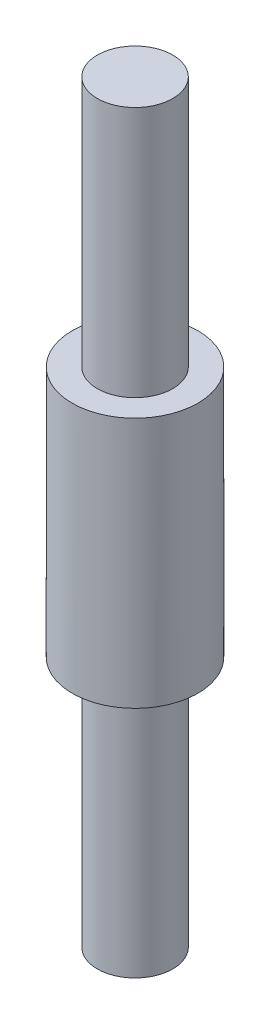
from build123d import *

# Parameters (mm, degrees)
SKETCH1_R           = 2.5
BOSS_EXTRUDE1_DEPTH = 15
SKETCH2_R           = 12.5
SKETCH2_R_2         = 1.5
CUT_EXTRUDE1_DEPTH  = 10


with BuildPart() as part:
    # Sketch1 → Boss-Extrude1 (new body, symmetric)
    with BuildSketch(Plane(origin=(0, 0, 0), x_dir=(1, 0, 0), z_dir=(0, 1, 0))):
        Circle(SKETCH1_R)
    extrude(amount=BOSS_EXTRUDE1_DEPTH, both=True)

    # Sketch2 → Cut-Extrude1 (cut)
    with BuildSketch(Plane(origin=(0, 15, 0), x_dir=(1, 0, 0), z_dir=(0, 1, 0))):
        Circle(SKETCH2_R)
        Circle(SKETCH2_R_2, mode=Mode.SUBTRACT)
    cut_extrude1 = extrude(amount=-CUT_EXTRUDE1_DEPTH, mode=Mode.SUBTRACT)

    # Mirror1: Cut-Extrude1 across plane
    add(cut_extrude1.mirror(Plane.ZX), mode=Mode.SUBTRACT)


solid = part.part
